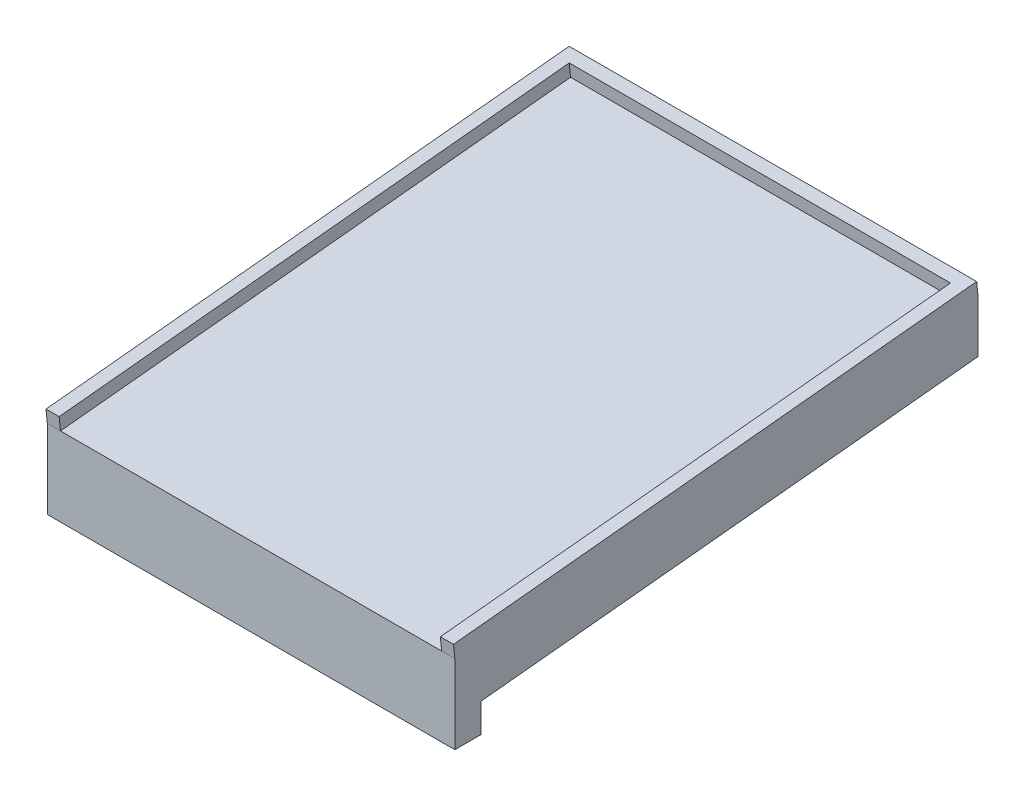
from build123d import *

# Parameters (mm, degrees)
BOSS_EXTRUDE1_DEPTH = 155
SKETCH7_W           = 155
SKETCH7_H           = 20
BOSS_EXTRUDE4_DEPTH = 10
SKETCH8_W           = 145
SKETCH8_H           = 5
BOSS_EXTRUDE5_DEPTH = 5


with BuildPart() as part:
    # Sketch4 → Boss-Extrude1 (new body)
    with BuildSketch(Plane(origin=(0, 0, 0), x_dir=(0, 0, -1), z_dir=(1, 0, 0))):
        Polygon((0, 0), (0, 20), (198.997487421, 40), (198.997487421, 20), align=None)
    extrude(amount=BOSS_EXTRUDE1_DEPTH)

    # Sketch7 → Boss-Extrude4 (add)
    with BuildSketch(Plane.XY):
        with Locations((77.5, 0)):
            Rectangle(SKETCH7_W, SKETCH7_H)
    extrude(amount=-BOSS_EXTRUDE4_DEPTH)

    # Sketch8 → Boss-Extrude5 (add)
    with BuildSketch(Plane(origin=(0, 19.8, 1.989974874), x_dir=(1, 0, 0), z_dir=(0, 0.994987437, 0.1))):
        Polygon((5, 202), (0, 202), (0, 2), (5, 2), (5, 197), align=None)
        with Locations((77.5, 199.5)):
            Rectangle(SKETCH8_W, SKETCH8_H)
        Polygon((155, 202), (150, 202), (150, 197), (150, 2), (155, 2), align=None)
    extrude(amount=BOSS_EXTRUDE5_DEPTH)


solid = part.part
